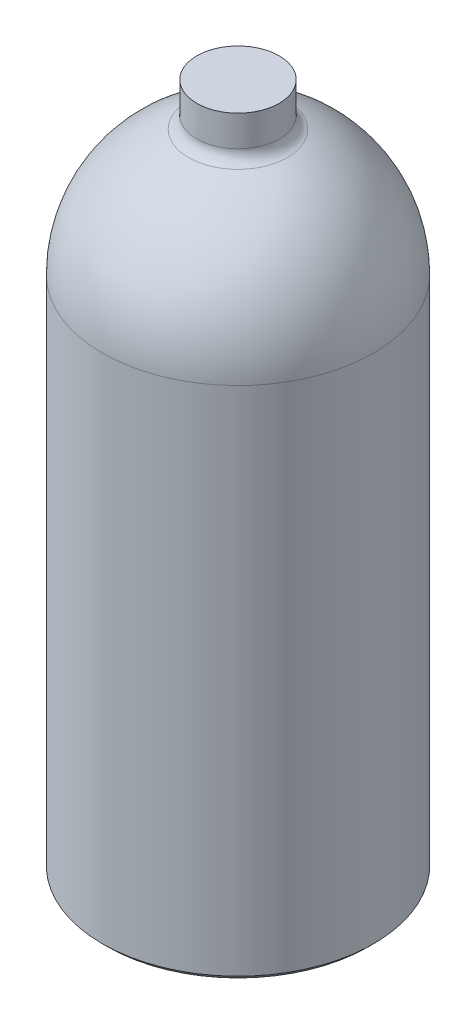
from build123d import *

# Parameters (mm, degrees)
SKETCH1_R           = 66.675
BOSS_EXTRUDE1_DEPTH = 127.0635
DOME1_FACE_RADIUS   = 66.675
DOME1_HEIGHT        = 66.675
SKETCH5_R           = 20.255
BOSS_EXTRUDE2_DEPTH = 16.51
CHAMFER1_SIZE       = 2.54
FILLET1_R           = 6.35


with BuildPart() as part:
    # Sketch1 → Boss-Extrude1 (new body, symmetric)
    with BuildSketch(Plane(origin=(0, 0, 0), x_dir=(1, 0, 0), z_dir=(0, 1, 0))):
        Circle(SKETCH1_R)
    extrude(amount=BOSS_EXTRUDE1_DEPTH, both=True)

    # Dome1: a dome of height H over a round flat face of radius A is a cap of a sphere of radius (A * A + H * H) / (2 * H)
    dome1_r = (DOME1_FACE_RADIUS * DOME1_FACE_RADIUS + DOME1_HEIGHT * DOME1_HEIGHT) / (2 * DOME1_HEIGHT)
    dome1_base = Plane((0, 127.0635, 0), z_dir=(0, 1, 0))
    with Locations(dome1_base.offset(DOME1_HEIGHT - dome1_r)):
        dome1_ball = Sphere(dome1_r, mode=Mode.PRIVATE)
    add(split(dome1_ball, bisect_by=dome1_base, keep=Keep.TOP, mode=Mode.PRIVATE))

    # Sketch5 → Boss-Extrude2 (add, symmetric)
    with BuildSketch(Plane(origin=(0, 193.7385, 0), x_dir=(1, 0, 0), z_dir=(0, 1, 0))):
        Circle(SKETCH5_R)
    extrude(amount=BOSS_EXTRUDE2_DEPTH, both=True)

    # Chamfer1
    chamfer1_edges = [part.edges().sort_by_distance(p)[0] for p in [
        (-66.675, -127.0635, 0),
    ]]
    chamfer(chamfer1_edges, length=CHAMFER1_SIZE)

    # Fillet1
    fillet1_edges = [part.edges().sort_by_distance(p)[0] for p in [
        (-14.322447853, 190.587437221, -14.322447853),
    ]]
    fillet(fillet1_edges, radius=FILLET1_R)


solid = part.part
